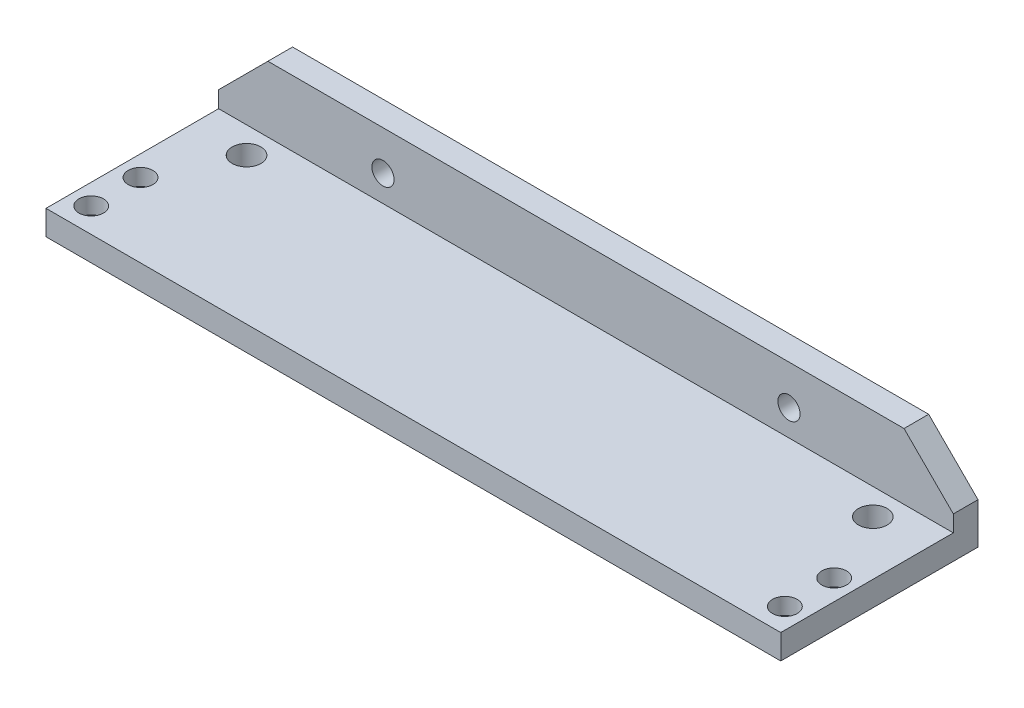
from build123d import *

# Parameters (mm, degrees)
SKETCH1_R           = 1.35
BOSS_EXTRUDE1_DEPTH = 3
SKETCH1_3_W         = 89.4
SKETCH1_3_H         = 3
BOSS_EXTRUDE2_DEPTH = 24
CUT_EXTRUDE1_REACH  = 5
SKETCH3_R           = 1.5
SKETCH3_R_2         = 1.75
CUT_EXTRUDE2_START  = -3
SKETCH3_5_R         = 2.25
SKETCH3_5_R_2       = 1.5
CUT_EXTRUDE2_DEPTH  = 1


with BuildPart() as part:
    # Sketch1 → Boss-Extrude1 (new body)
    with BuildSketch(Plane.XY):
        Polygon((-32.2510699, 8.892599614), (-38.2510699, 2.892599614), (-38.2510699, 0.892599614), (51.1489301, 0.892599614), (51.1489301, 2.892599614), (45.1489301, 8.892599614), align=None)
        with Locations((-18.2510699, 4.092599614)):
            Circle(SKETCH1_R, mode=Mode.SUBTRACT)
        with Locations((31.1489301, 4.092599614)):
            Circle(SKETCH1_R, mode=Mode.SUBTRACT)
    extrude(amount=BOSS_EXTRUDE1_DEPTH)

    # Sketch1_3 → Boss-Extrude2 (add)
    with BuildSketch(Plane.XY):
        with Locations((6.4489301, -0.607400386)):
            Rectangle(SKETCH1_3_W, SKETCH1_3_H)
    extrude(amount=BOSS_EXTRUDE2_DEPTH)

    # Sketch3 → Cut-Extrude1 (cut, up to next)
    with BuildSketch(Plane(origin=(0, 0.892599614, 0), x_dir=(1, 0, 0), z_dir=(0, 1, 0)), mode=Mode.PRIVATE) as cut_extrude1_sk1:
        with Locations((48.6489301, -15)):
            Circle(SKETCH3_R)
    cut_extrude1_tool1 = extrude(cut_extrude1_sk1.sketch, amount=-CUT_EXTRUDE1_REACH, mode=Mode.PRIVATE) & part.part
    add(cut_extrude1_tool1.solids().sort_by_distance((48.64893, 0.8926, 15))[0], mode=Mode.SUBTRACT)
    # Sketch3 → Cut-Extrude1 (cut, up to next)
    with BuildSketch(Plane(origin=(0, 0.892599614, 0), x_dir=(1, 0, 0), z_dir=(0, 1, 0)), mode=Mode.PRIVATE) as cut_extrude1_sk2:
        with Locations((48.6489301, -21)):
            Circle(SKETCH3_R)
    cut_extrude1_tool2 = extrude(cut_extrude1_sk2.sketch, amount=-CUT_EXTRUDE1_REACH, mode=Mode.PRIVATE) & part.part
    add(cut_extrude1_tool2.solids().sort_by_distance((48.64893, 0.8926, 21))[0], mode=Mode.SUBTRACT)
    # Sketch3 → Cut-Extrude1 (cut, up to next)
    with BuildSketch(Plane(origin=(0, 0.892599614, 0), x_dir=(1, 0, 0), z_dir=(0, 1, 0)), mode=Mode.PRIVATE) as cut_extrude1_sk3:
        with Locations((-35.7510699, -15)):
            Circle(SKETCH3_R)
    cut_extrude1_tool3 = extrude(cut_extrude1_sk3.sketch, amount=-CUT_EXTRUDE1_REACH, mode=Mode.PRIVATE) & part.part
    add(cut_extrude1_tool3.solids().sort_by_distance((-35.75107, 0.8926, 15))[0], mode=Mode.SUBTRACT)
    # Sketch3 → Cut-Extrude1 (cut, up to next)
    with BuildSketch(Plane(origin=(0, 0.892599614, 0), x_dir=(1, 0, 0), z_dir=(0, 1, 0)), mode=Mode.PRIVATE) as cut_extrude1_sk4:
        with Locations((-35.7510699, -21)):
            Circle(SKETCH3_R)
    cut_extrude1_tool4 = extrude(cut_extrude1_sk4.sketch, amount=-CUT_EXTRUDE1_REACH, mode=Mode.PRIVATE) & part.part
    add(cut_extrude1_tool4.solids().sort_by_distance((-35.75107, 0.8926, 21))[0], mode=Mode.SUBTRACT)
    # Sketch3 → Cut-Extrude1 (cut, up to next)
    with BuildSketch(Plane(origin=(0, 0.892599614, 0), x_dir=(1, 0, 0), z_dir=(0, 1, 0)), mode=Mode.PRIVATE) as cut_extrude1_sk5:
        with Locations((44.5489301, -6.2)):
            Circle(SKETCH3_R_2)
    cut_extrude1_tool5 = extrude(cut_extrude1_sk5.sketch, amount=-CUT_EXTRUDE1_REACH, mode=Mode.PRIVATE) & part.part
    add(cut_extrude1_tool5.solids().sort_by_distance((44.54893, 0.8926, 6.2))[0], mode=Mode.SUBTRACT)
    # Sketch3 → Cut-Extrude1 (cut, up to next)
    with BuildSketch(Plane(origin=(0, 0.892599614, 0), x_dir=(1, 0, 0), z_dir=(0, 1, 0)), mode=Mode.PRIVATE) as cut_extrude1_sk6:
        with Locations((-31.6510699, -6.2)):
            Circle(SKETCH3_R_2)
    cut_extrude1_tool6 = extrude(cut_extrude1_sk6.sketch, amount=-CUT_EXTRUDE1_REACH, mode=Mode.PRIVATE) & part.part
    add(cut_extrude1_tool6.solids().sort_by_distance((-31.65107, 0.8926, 6.2))[0], mode=Mode.SUBTRACT)

    # Sketch3_5 → Cut-Extrude2 (cut)
    with BuildSketch(Plane(origin=(0, 0.892599614, 0), x_dir=(1, 0, 0), z_dir=(0, 1, 0)).offset(CUT_EXTRUDE2_START)):
        with Locations((-35.7510699, -15)):
            Circle(SKETCH3_5_R)
        with Locations((-35.7510699, -15)):
            Circle(SKETCH3_5_R_2, mode=Mode.SUBTRACT)
        with Locations((-35.7510699, -21)):
            Circle(SKETCH3_5_R)
        with Locations((-35.7510699, -21)):
            Circle(SKETCH3_5_R_2, mode=Mode.SUBTRACT)
        with Locations((48.6489301, -15)):
            Circle(SKETCH3_5_R)
        with Locations((48.6489301, -21)):
            Circle(SKETCH3_5_R)
    extrude(amount=CUT_EXTRUDE2_DEPTH, mode=Mode.SUBTRACT)


solid = part.part
